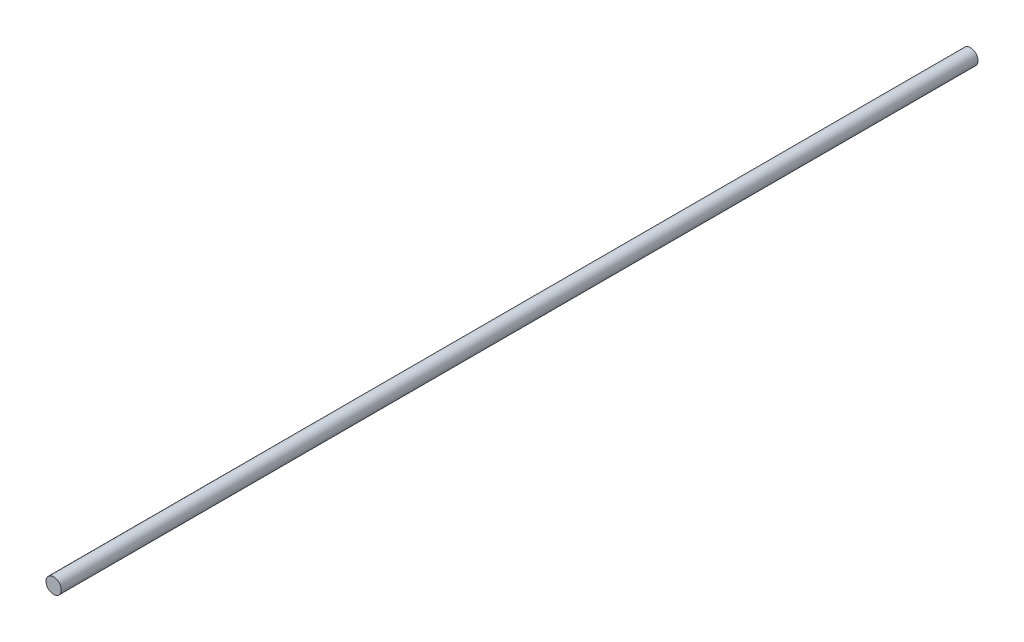
from build123d import *

# Parameters (mm, degrees)
SKETCH1_R           = 2.5
BOSS_EXTRUDE1_DEPTH = 300


with BuildPart() as part:
    # Sketch1 → Boss-Extrude1 (new body)
    with BuildSketch(Plane.XY):
        with Locations((0.143759197, 0.944423649)):
            Circle(SKETCH1_R)
    extrude(amount=BOSS_EXTRUDE1_DEPTH)


solid = part.part
